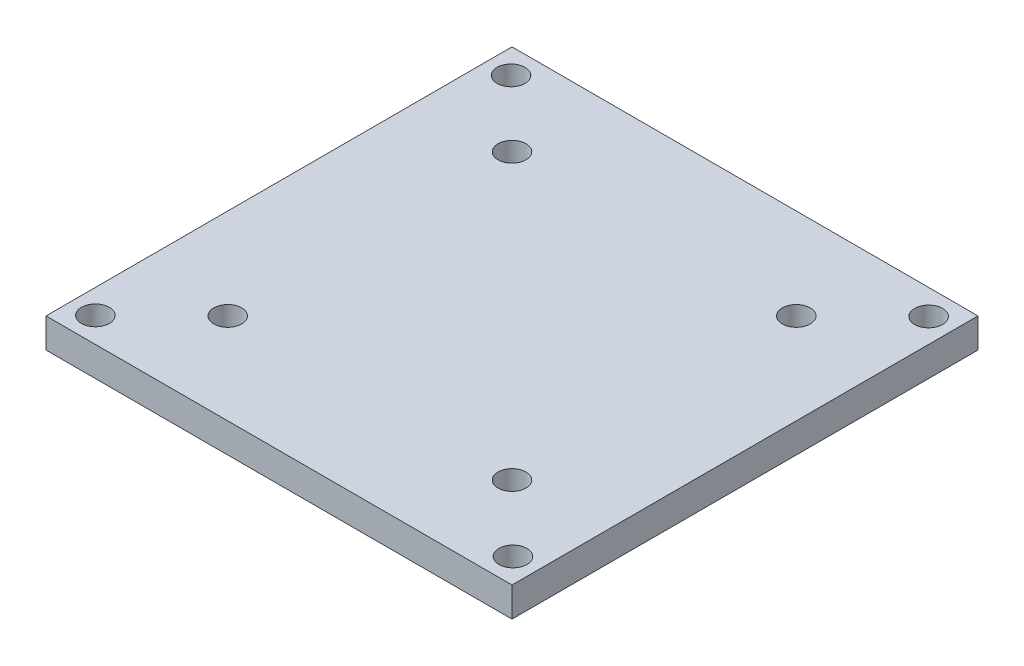
from build123d import *

# Parameters (mm, degrees)
SKETCH1_W           = 50
SKETCH1_H           = 50
SKETCH1_R           = 1.5
BOSS_EXTRUDE1_DEPTH = 3.175


with BuildPart() as part:
    # Sketch1 → Boss-Extrude1 (new body)
    with BuildSketch(Plane(origin=(0, 0, 0), x_dir=(1, 0, 0), z_dir=(0, 1, 0))):
        Rectangle(SKETCH1_W, SKETCH1_H)
        with Locations((-22.4, 22.3)):
            Circle(SKETCH1_R, mode=Mode.SUBTRACT)
        with Locations((22.4, 22.3)):
            Circle(SKETCH1_R, mode=Mode.SUBTRACT)
        with Locations((22.4, -22.3)):
            Circle(SKETCH1_R, mode=Mode.SUBTRACT)
        with Locations((-22.4, -22.3)):
            Circle(SKETCH1_R, mode=Mode.SUBTRACT)
        with Locations((-15.25, 15.25)):
            Circle(SKETCH1_R, mode=Mode.SUBTRACT)
        with Locations((15.25, 15.25)):
            Circle(SKETCH1_R, mode=Mode.SUBTRACT)
        with Locations((15.25, -15.25)):
            Circle(SKETCH1_R, mode=Mode.SUBTRACT)
        with Locations((-15.25, -15.25)):
            Circle(SKETCH1_R, mode=Mode.SUBTRACT)
    extrude(amount=BOSS_EXTRUDE1_DEPTH)


solid = part.part
